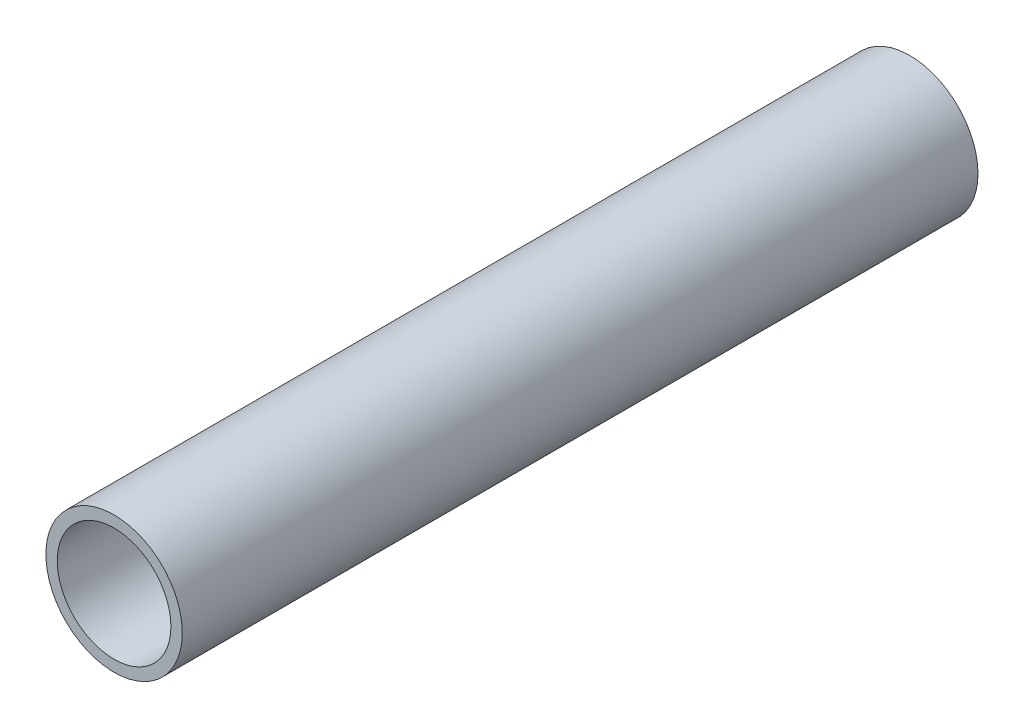
from build123d import *

# Parameters (mm, degrees)
SCHIZZO1_R                   = 12
SCHIZZO1_R_2                 = 10
ESTRUSIONE_ESTRUSIONE1_DEPTH = 140


with BuildPart() as part:
    # Schizzo1 → Estrusione-Estrusione1 (new body)
    with BuildSketch(Plane.XY):
        Circle(SCHIZZO1_R)
        Circle(SCHIZZO1_R_2, mode=Mode.SUBTRACT)
    extrude(amount=ESTRUSIONE_ESTRUSIONE1_DEPTH)


solid = part.part
